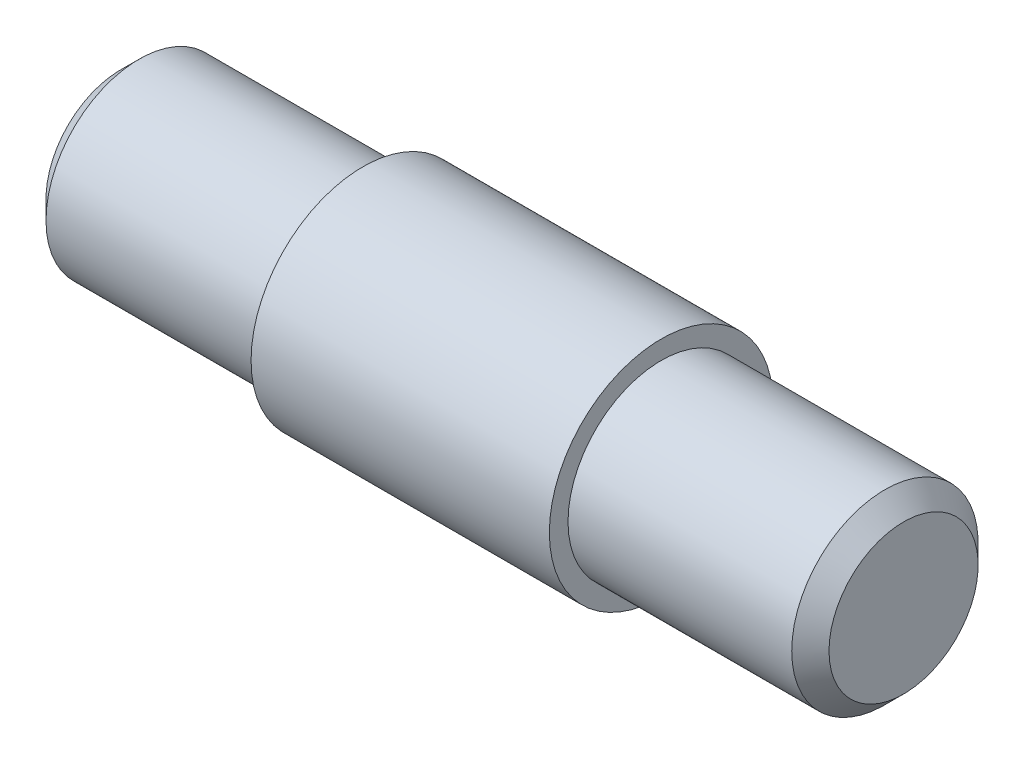
from build123d import *

# Parameters (mm, degrees)
CHANFREIN1_SIZE = 0.5


with BuildPart() as part:
    # Esquisse1 → Révolution1 (revolve)
    with BuildSketch(Plane.XY):
        Polygon((0, 0), (0, 2.5), (6.5, 2.5), (6.5, 3), (14.5, 3), (14.5, 2.5), (21, 2.5), (21, 0), align=None)
    revolve(axis=Axis((-54.824636662, 0, 0), (1, 0, 0)))

    # Chanfrein1
    chanfrein1_edges = [part.edges().sort_by_distance(p)[0] for p in [
        (21, -2.5, 0),
        (0, -2.5, 0),
    ]]
    chamfer(chanfrein1_edges, length=CHANFREIN1_SIZE)


solid = part.part
